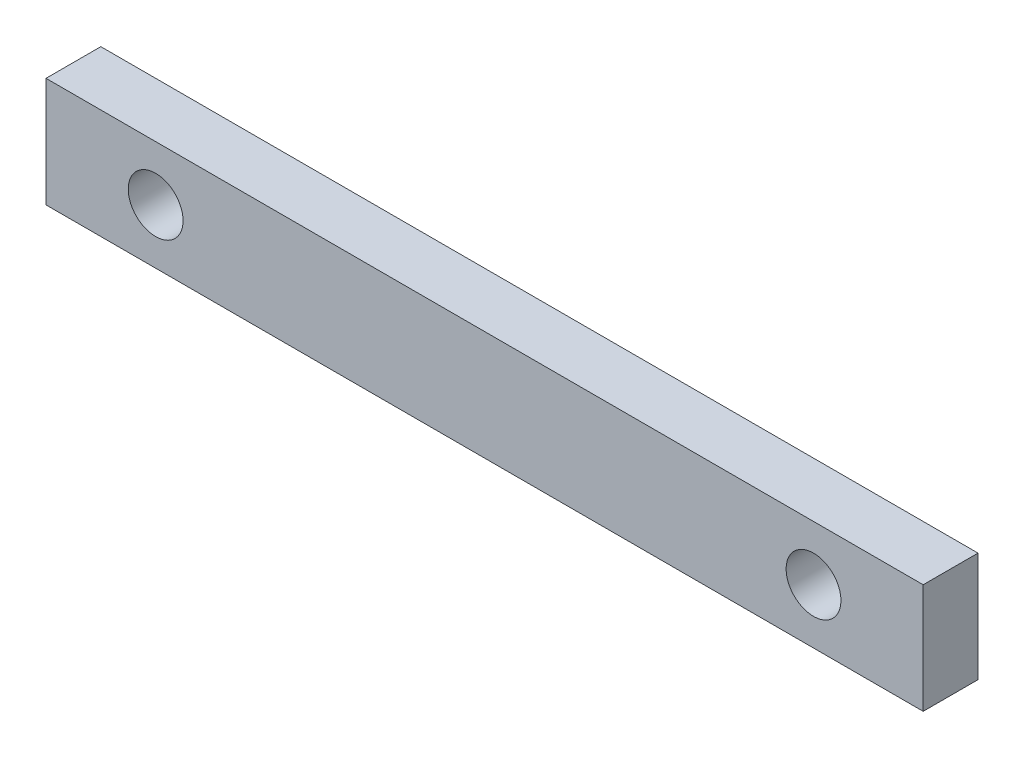
from build123d import *

# Parameters (mm, degrees)
SKETCH1_W           = 80
SKETCH1_H           = 10
SKETCH1_R           = 2.5
BOSS_EXTRUDE1_DEPTH = 5


with BuildPart() as part:
    # Sketch1 → Boss-Extrude1 (new body)
    with BuildSketch(Plane.XY):
        Rectangle(SKETCH1_W, SKETCH1_H)
        with Locations((-30, 0)):
            Circle(SKETCH1_R, mode=Mode.SUBTRACT)
        with Locations((30, 0)):
            Circle(SKETCH1_R, mode=Mode.SUBTRACT)
    extrude(amount=BOSS_EXTRUDE1_DEPTH)


solid = part.part
